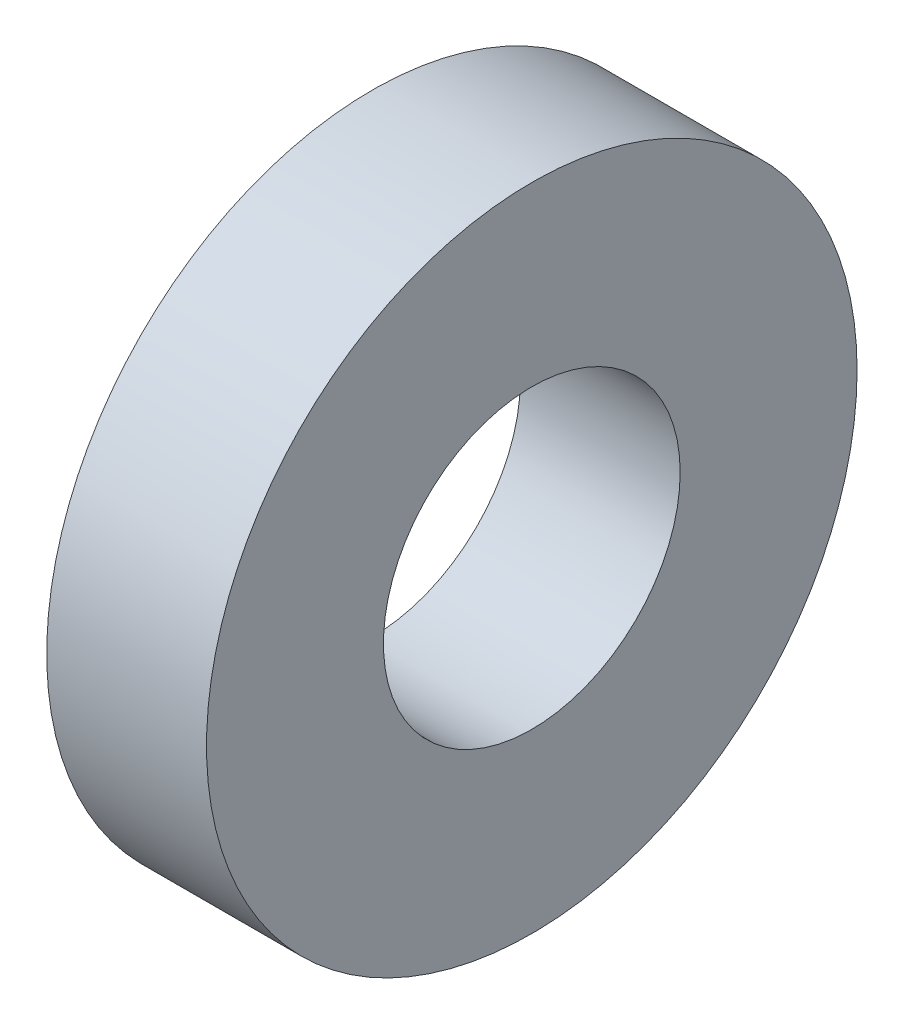
from build123d import *

# Parameters (mm, degrees)
SKETCH1_R           = 3.6195
SKETCH1_R_2         = 1.651
BOSS_EXTRUDE1_DEPTH = 1.778


with BuildPart() as part:
    # Sketch1 → Boss-Extrude1 (new body)
    with BuildSketch(Plane(origin=(0, 0, 0), x_dir=(0, 0, -1), z_dir=(1, 0, 0))):
        Circle(SKETCH1_R)
        Circle(SKETCH1_R_2, mode=Mode.SUBTRACT)
    extrude(amount=BOSS_EXTRUDE1_DEPTH)


solid = part.part
